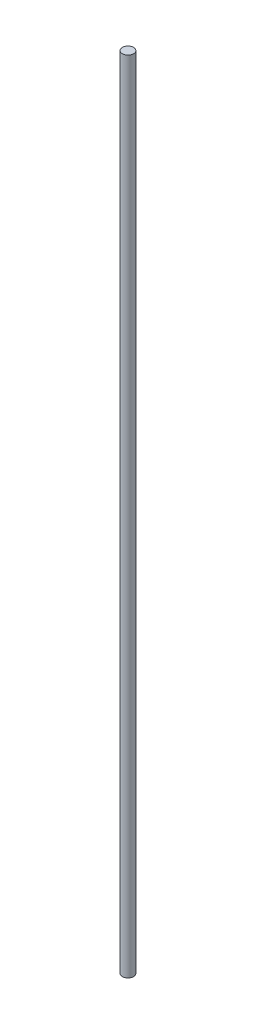
from build123d import *

# Parameters (mm, degrees)
SKETCH1_R           = 2.5
BOSS_EXTRUDE1_DEPTH = 358.5


with BuildPart() as part:
    # Sketch1 → Boss-Extrude1 (new body)
    with BuildSketch(Plane(origin=(0, 0, 0), x_dir=(1, 0, 0), z_dir=(0, 1, 0))):
        Circle(SKETCH1_R)
    extrude(amount=BOSS_EXTRUDE1_DEPTH)


solid = part.part
